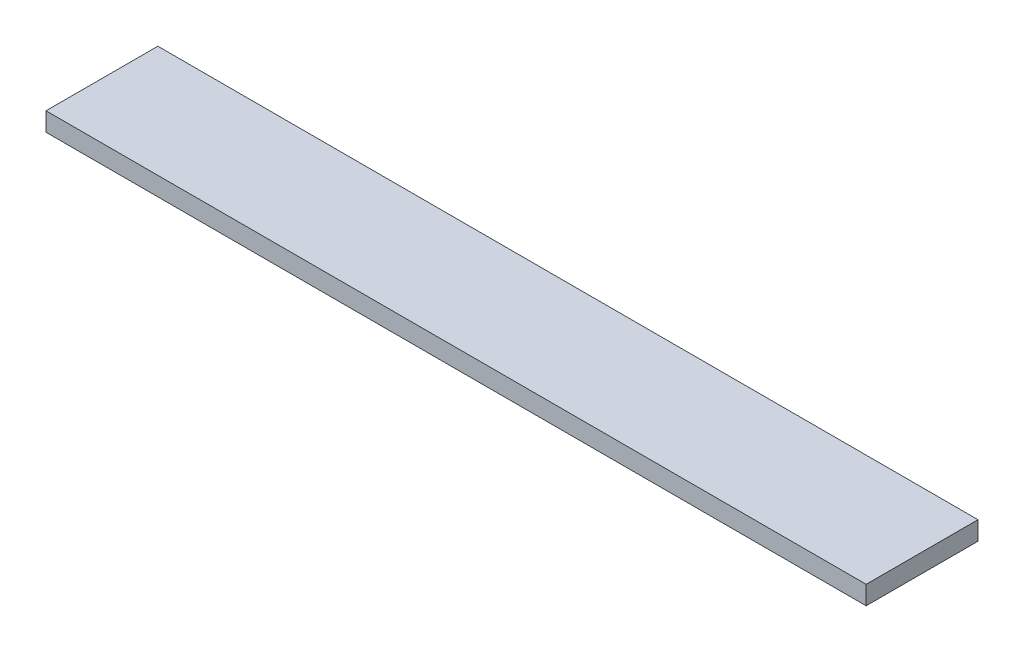
from build123d import *

# Parameters (mm, degrees)
SKETCH1_W           = 139.7
SKETCH1_H           = 19.05
BOSS_EXTRUDE1_DEPTH = 3.175


with BuildPart() as part:
    # Sketch1 → Boss-Extrude1 (new body)
    with BuildSketch(Plane(origin=(0, 0, 0), x_dir=(1, 0, 0), z_dir=(0, 1, 0))):
        with Locations((69.85, -9.525)):
            Rectangle(SKETCH1_W, SKETCH1_H)
    extrude(amount=BOSS_EXTRUDE1_DEPTH)


solid = part.part
